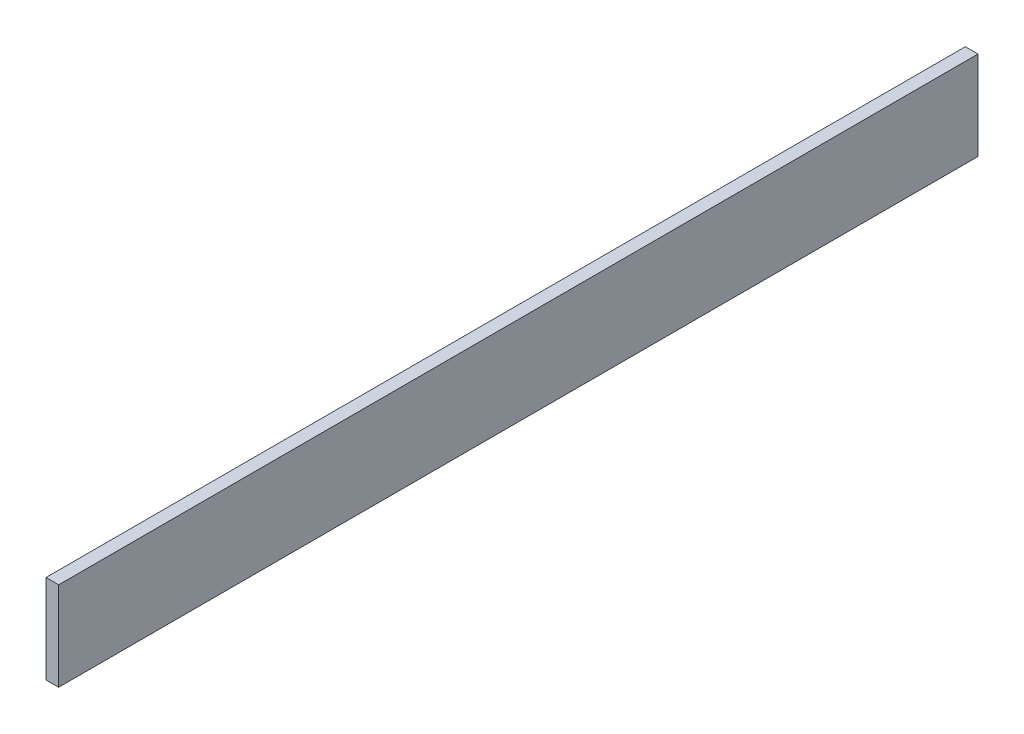
from build123d import *

# Parameters (mm, degrees)
SKETCH1_W           = 10
SKETCH1_H           = 725
BOSS_EXTRUDE1_DEPTH = 70


with BuildPart() as part:
    # Sketch1 → Boss-Extrude1 (new body)
    with BuildSketch(Plane(origin=(0, 0, 0), x_dir=(1, 0, 0), z_dir=(0, 1, 0))):
        Rectangle(SKETCH1_W, SKETCH1_H)
    extrude(amount=BOSS_EXTRUDE1_DEPTH)


solid = part.part
